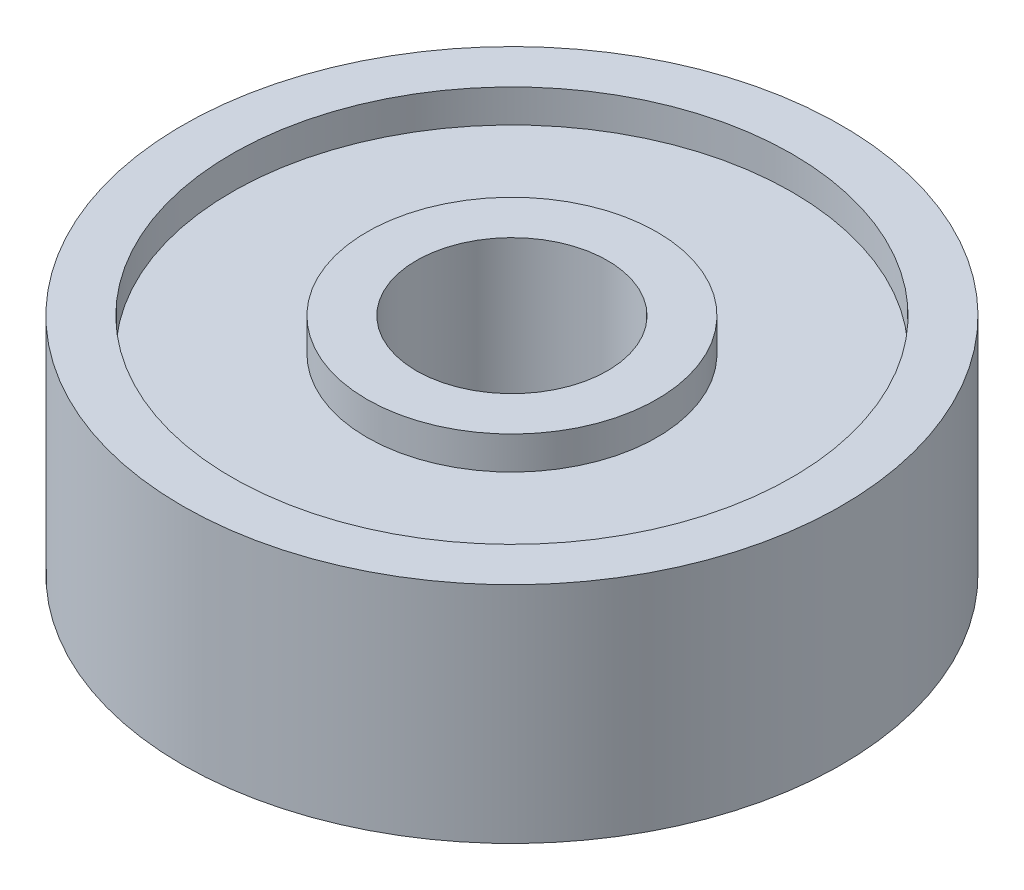
from build123d import *

# Parameters (mm, degrees)
SKETCH_1_R          = 100
SKETCH_1_R_2        = 29
EXTRUDE_1_DEPTH     = 34
SKETCH_2_R          = 85
SKETCH_2_R_2        = 44
CUT_EXTRUDE_1_DEPTH = 10


with BuildPart() as part:
    # 草图1 → 凸台-拉伸1 (new body, symmetric)
    with BuildSketch(Plane(origin=(0, 0, 0), x_dir=(1, 0, 0), z_dir=(0, 1, 0))):
        Circle(SKETCH_1_R)
        Circle(SKETCH_1_R_2, mode=Mode.SUBTRACT)
    extrude(amount=EXTRUDE_1_DEPTH, both=True)

    # 草图2 → 切除-拉伸1 (cut)
    with BuildSketch(Plane.XZ.offset(34)):
        Circle(SKETCH_2_R)
        Circle(SKETCH_2_R_2, mode=Mode.SUBTRACT)
    cut_extrude_1 = extrude(amount=-CUT_EXTRUDE_1_DEPTH, mode=Mode.SUBTRACT)

    # 镜向1: 切除-拉伸1 across plane
    add(cut_extrude_1.mirror(Plane.ZX), mode=Mode.SUBTRACT)


solid = part.part
